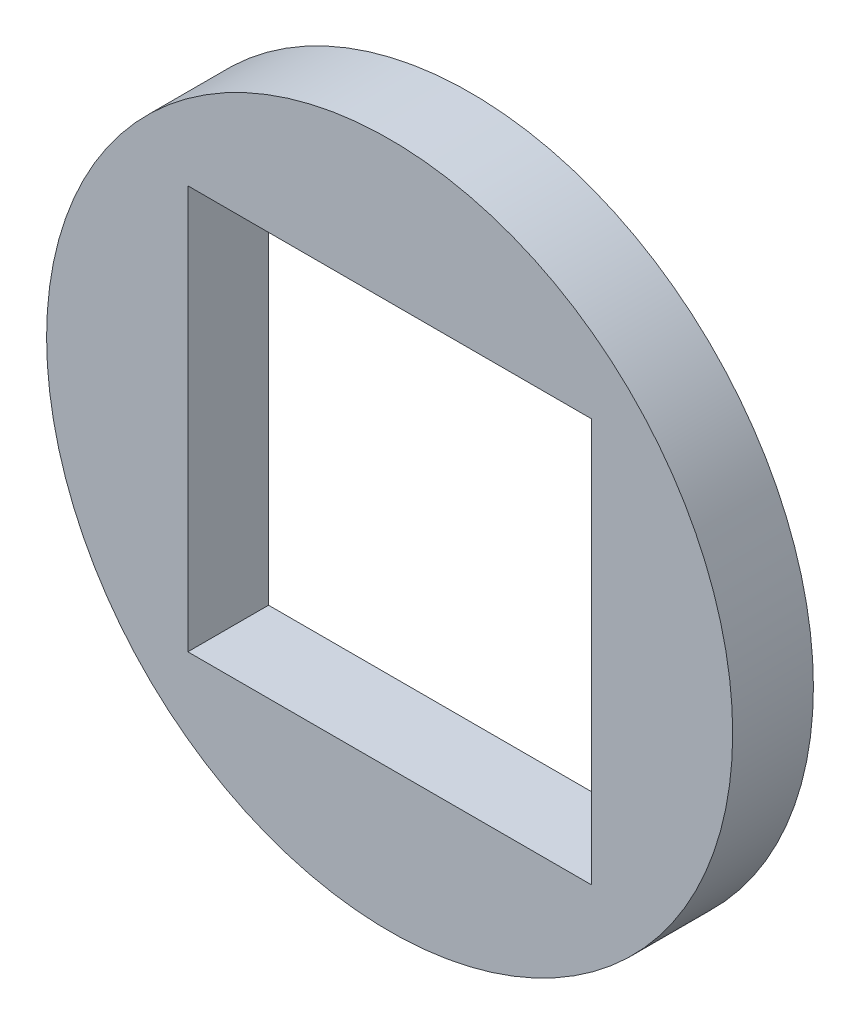
from build123d import *

# Parameters (mm, degrees)
MODEL_R             = 8.5
MODEL_W             = 10
MODEL_H             = 10
BOSS_EXTRUDE1_DEPTH = 2


with BuildPart() as part:
    # Model → Boss-Extrude1 (new body)
    with BuildSketch(Plane.XY):
        Circle(MODEL_R)
        Rectangle(MODEL_W, MODEL_H, mode=Mode.SUBTRACT)
    extrude(amount=BOSS_EXTRUDE1_DEPTH)


solid = part.part
